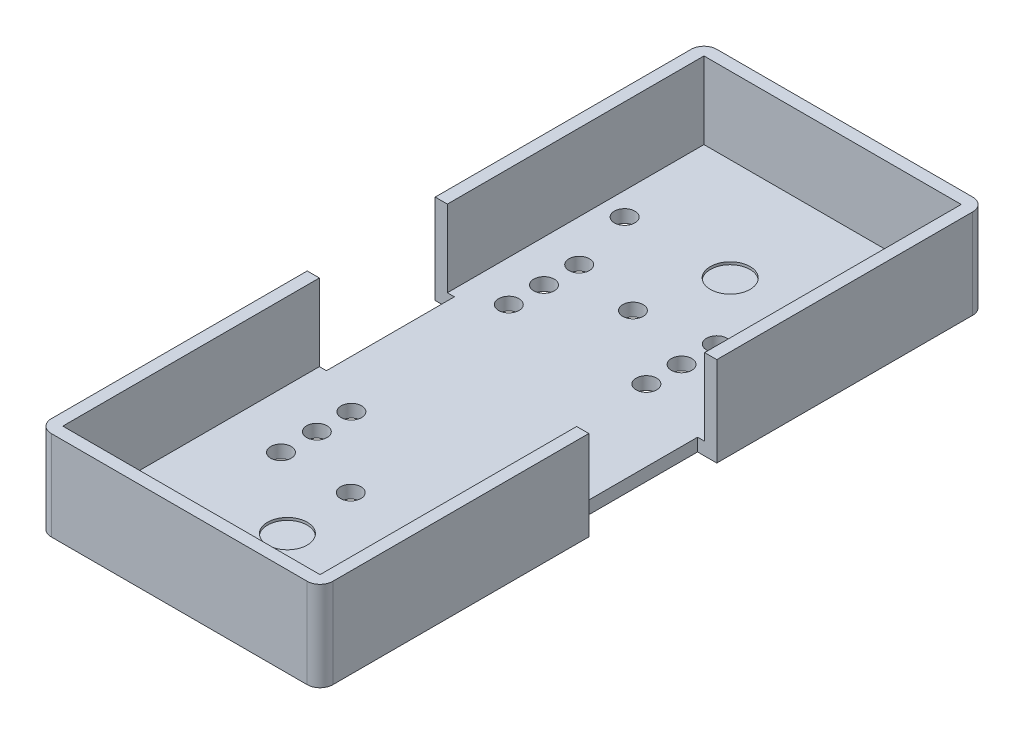
from build123d import *

# Parameters (mm, degrees)
SKETCH1_W               = 22
SKETCH1_H               = 52
BOSS_EXTRUDE1_DEPTH     = 7
SKETCH2_W               = 20.1
SKETCH2_H               = 50.1
CUT_EXTRUDE1_DEPTH      = 6
FILLET1_R               = 1
SKETCH4_W               = 1.5
SKETCH4_H               = 10
CUT_EXTRUDE3_DEPTH      = 8
SKETCH5_R               = 1.55
CUT_EXTRUDE4_DEPTH      = 0.2
SKETCH6_R               = 1.55
CUT_EXTRUDE5_DEPTH      = 0.2
SKETCH7_R               = 0.8
CUT_EXTRUDE6_DEPTH      = 7
CUT_EXTRUDE6_DEPTH_BACK = 2
CUT_EXTRUDE7_REACH      = 3
SKETCH8_R               = 0.8
CUT_EXTRUDE9_REACH      = 3
SKETCH9_R               = 0.8
CUT_EXTRUDE10_REACH     = 3
SKETCH10_R              = 0.8
CUT_EXTRUDE11_REACH     = 3
SKETCH11_R              = 0.8
CUT_EXTRUDE12_REACH     = 3
SKETCH12_R              = 0.8
CUT_EXTRUDE13_REACH     = 3
SKETCH13_R              = 0.8
CUT_EXTRUDE14_REACH     = 3
SKETCH14_R              = 0.8
CUT_EXTRUDE15_REACH     = 3
SKETCH15_R              = 0.8
CUT_EXTRUDE16_REACH     = 3
SKETCH16_R              = 0.8


with BuildPart() as part:
    # Sketch1 → Boss-Extrude1 (new body)
    with BuildSketch(Plane(origin=(0, 0, 0), x_dir=(1, 0, 0), z_dir=(0, 1, 0))):
        Rectangle(SKETCH1_W, SKETCH1_H)
    extrude(amount=BOSS_EXTRUDE1_DEPTH)

    # Sketch2 → Cut-Extrude1 (cut)
    with BuildSketch(Plane(origin=(0, 7, 0), x_dir=(1, 0, 0), z_dir=(0, 1, 0))):
        Rectangle(SKETCH2_W, SKETCH2_H)
    extrude(amount=-CUT_EXTRUDE1_DEPTH, mode=Mode.SUBTRACT)

    # Fillet1
    fillet1_edges = [part.edges().sort_by_distance(p)[0] for p in [
        (11, 3.5, 26),
        (-11, 3.5, 26),
        (-11, 3.5, -26),
        (11, 3.5, -26),
    ]]
    fillet(fillet1_edges, radius=FILLET1_R)

    # Sketch4 → Cut-Extrude3 (cut, through all)
    with BuildSketch(Plane.XZ):
        with Locations((-10.25, 0)):
            Rectangle(SKETCH4_W, SKETCH4_H)
        with Locations((10.25, 0)):
            Rectangle(SKETCH4_W, SKETCH4_H)
    extrude(amount=-CUT_EXTRUDE3_DEPTH, mode=Mode.SUBTRACT)

    # Sketch5 → Cut-Extrude4 (cut)
    with BuildSketch(Plane(origin=(0, 1, 0), x_dir=(1, 0, 0), z_dir=(0, 1, 0))):
        with Locations((0, -17.55)):
            Circle(SKETCH5_R)
    extrude(amount=-CUT_EXTRUDE4_DEPTH, mode=Mode.SUBTRACT)

    # Sketch6 → Cut-Extrude5 (cut)
    with BuildSketch(Plane(origin=(0, 1, 0), x_dir=(1, 0, 0), z_dir=(0, 1, 0))):
        with Locations((0, 17.05)):
            Circle(SKETCH6_R)
    extrude(amount=-CUT_EXTRUDE5_DEPTH, mode=Mode.SUBTRACT)

    # Sketch7 → Cut-Extrude6 (cut, two sides)
    with BuildSketch(Plane(origin=(0, 1, 0), x_dir=(1, 0, 0), z_dir=(0, 1, 0))) as cut_extrude6_sk:
        with Locations((-8.15, -23)):
            Circle(SKETCH7_R)
    extrude(amount=CUT_EXTRUDE6_DEPTH, mode=Mode.SUBTRACT)
    extrude(cut_extrude6_sk.sketch, amount=-CUT_EXTRUDE6_DEPTH_BACK, mode=Mode.SUBTRACT)

    # Sketch8 → Cut-Extrude7 (cut, up to next)
    with BuildSketch(Plane(origin=(0, 1, 0), x_dir=(1, 0, 0), z_dir=(0, 1, 0)), mode=Mode.PRIVATE) as cut_extrude7_sk1:
        with Locations((-5.75, -12.3)):
            Circle(SKETCH8_R)
    cut_extrude7_tool1 = extrude(cut_extrude7_sk1.sketch, amount=-CUT_EXTRUDE7_REACH, mode=Mode.PRIVATE) & part.part
    add(cut_extrude7_tool1.solids().sort_by_distance((-5.75, 1, 12.3))[0], mode=Mode.SUBTRACT)
    # Sketch8 → Cut-Extrude7 (cut, up to next)
    with BuildSketch(Plane(origin=(0, 1, 0), x_dir=(1, 0, 0), z_dir=(0, 1, 0)), mode=Mode.PRIVATE) as cut_extrude7_sk2:
        with Locations((5, -12.3)):
            Circle(SKETCH8_R)
    cut_extrude7_tool2 = extrude(cut_extrude7_sk2.sketch, amount=-CUT_EXTRUDE7_REACH, mode=Mode.PRIVATE) & part.part
    add(cut_extrude7_tool2.solids().sort_by_distance((5, 1, 12.3))[0], mode=Mode.SUBTRACT)

    # Sketch9 → Cut-Extrude9 (cut, up to next)
    with BuildSketch(Plane(origin=(0, 1, 0), x_dir=(1, 0, 0), z_dir=(0, 1, 0)), mode=Mode.PRIVATE) as cut_extrude9_sk1:
        with Locations((-5.75, -9.5)):
            Circle(SKETCH9_R)
    cut_extrude9_tool1 = extrude(cut_extrude9_sk1.sketch, amount=-CUT_EXTRUDE9_REACH, mode=Mode.PRIVATE) & part.part
    add(cut_extrude9_tool1.solids().sort_by_distance((-5.75, 1, 9.5))[0], mode=Mode.SUBTRACT)
    # Sketch9 → Cut-Extrude9 (cut, up to next)
    with BuildSketch(Plane(origin=(0, 1, 0), x_dir=(1, 0, 0), z_dir=(0, 1, 0)), mode=Mode.PRIVATE) as cut_extrude9_sk2:
        with Locations((5, -9.5)):
            Circle(SKETCH9_R)
    cut_extrude9_tool2 = extrude(cut_extrude9_sk2.sketch, amount=-CUT_EXTRUDE9_REACH, mode=Mode.PRIVATE) & part.part
    add(cut_extrude9_tool2.solids().sort_by_distance((5, 1, 9.5))[0], mode=Mode.SUBTRACT)

    # Sketch10 → Cut-Extrude10 (cut, up to next)
    with BuildSketch(Plane(origin=(0, 1, 0), x_dir=(1, 0, 0), z_dir=(0, 1, 0)), mode=Mode.PRIVATE) as cut_extrude10_sk1:
        with Locations((-5.75, -6.8)):
            Circle(SKETCH10_R)
    cut_extrude10_tool1 = extrude(cut_extrude10_sk1.sketch, amount=-CUT_EXTRUDE10_REACH, mode=Mode.PRIVATE) & part.part
    add(cut_extrude10_tool1.solids().sort_by_distance((-5.75, 1, 6.8))[0], mode=Mode.SUBTRACT)
    # Sketch10 → Cut-Extrude10 (cut, up to next)
    with BuildSketch(Plane(origin=(0, 1, 0), x_dir=(1, 0, 0), z_dir=(0, 1, 0)), mode=Mode.PRIVATE) as cut_extrude10_sk2:
        with Locations((5, -6.837159935)):
            Circle(SKETCH10_R)
    cut_extrude10_tool2 = extrude(cut_extrude10_sk2.sketch, amount=-CUT_EXTRUDE10_REACH, mode=Mode.PRIVATE) & part.part
    add(cut_extrude10_tool2.solids().sort_by_distance((5, 1, 6.83716))[0], mode=Mode.SUBTRACT)

    # Sketch11 → Cut-Extrude11 (cut, up to next)
    with BuildSketch(Plane(origin=(0, 1, 0), x_dir=(1, 0, 0), z_dir=(0, 1, 0)), mode=Mode.PRIVATE) as cut_extrude11_sk1:
        with Locations((-0.3, -12.3)):
            Circle(SKETCH11_R)
    cut_extrude11_tool1 = extrude(cut_extrude11_sk1.sketch, amount=-CUT_EXTRUDE11_REACH, mode=Mode.PRIVATE) & part.part
    add(cut_extrude11_tool1.solids().sort_by_distance((-0.3, 1, 12.3))[0], mode=Mode.SUBTRACT)

    # Sketch12 → Cut-Extrude12 (cut, up to next)
    with BuildSketch(Plane(origin=(0, 1, 0), x_dir=(1, 0, 0), z_dir=(0, 1, 0)), mode=Mode.PRIVATE) as cut_extrude12_sk1:
        with Locations((3.95, 12.05)):
            Circle(SKETCH12_R)
    cut_extrude12_tool1 = extrude(cut_extrude12_sk1.sketch, amount=-CUT_EXTRUDE12_REACH, mode=Mode.PRIVATE) & part.part
    add(cut_extrude12_tool1.solids().sort_by_distance((3.95, 1, -12.05))[0], mode=Mode.SUBTRACT)
    # Sketch12 → Cut-Extrude12 (cut, up to next)
    with BuildSketch(Plane(origin=(0, 1, 0), x_dir=(1, 0, 0), z_dir=(0, 1, 0)), mode=Mode.PRIVATE) as cut_extrude12_sk2:
        with Locations((-6.8, 12.05)):
            Circle(SKETCH12_R)
    cut_extrude12_tool2 = extrude(cut_extrude12_sk2.sketch, amount=-CUT_EXTRUDE12_REACH, mode=Mode.PRIVATE) & part.part
    add(cut_extrude12_tool2.solids().sort_by_distance((-6.8, 1, -12.05))[0], mode=Mode.SUBTRACT)

    # Sketch13 → Cut-Extrude13 (cut, up to next)
    with BuildSketch(Plane(origin=(0, 1, 0), x_dir=(1, 0, 0), z_dir=(0, 1, 0)), mode=Mode.PRIVATE) as cut_extrude13_sk1:
        with Locations((3.95, 9.3)):
            Circle(SKETCH13_R)
    cut_extrude13_tool1 = extrude(cut_extrude13_sk1.sketch, amount=-CUT_EXTRUDE13_REACH, mode=Mode.PRIVATE) & part.part
    add(cut_extrude13_tool1.solids().sort_by_distance((3.95, 1, -9.3))[0], mode=Mode.SUBTRACT)
    # Sketch13 → Cut-Extrude13 (cut, up to next)
    with BuildSketch(Plane(origin=(0, 1, 0), x_dir=(1, 0, 0), z_dir=(0, 1, 0)), mode=Mode.PRIVATE) as cut_extrude13_sk2:
        with Locations((-6.8, 9.3)):
            Circle(SKETCH13_R)
    cut_extrude13_tool2 = extrude(cut_extrude13_sk2.sketch, amount=-CUT_EXTRUDE13_REACH, mode=Mode.PRIVATE) & part.part
    add(cut_extrude13_tool2.solids().sort_by_distance((-6.8, 1, -9.3))[0], mode=Mode.SUBTRACT)

    # Sketch14 → Cut-Extrude14 (cut, up to next)
    with BuildSketch(Plane(origin=(0, 1, 0), x_dir=(1, 0, 0), z_dir=(0, 1, 0)), mode=Mode.PRIVATE) as cut_extrude14_sk1:
        with Locations((3.9, 6.6)):
            Circle(SKETCH14_R)
    cut_extrude14_tool1 = extrude(cut_extrude14_sk1.sketch, amount=-CUT_EXTRUDE14_REACH, mode=Mode.PRIVATE) & part.part
    add(cut_extrude14_tool1.solids().sort_by_distance((3.9, 1, -6.6))[0], mode=Mode.SUBTRACT)
    # Sketch14 → Cut-Extrude14 (cut, up to next)
    with BuildSketch(Plane(origin=(0, 1, 0), x_dir=(1, 0, 0), z_dir=(0, 1, 0)), mode=Mode.PRIVATE) as cut_extrude14_sk2:
        with Locations((-6.85, 6.6)):
            Circle(SKETCH14_R)
    cut_extrude14_tool2 = extrude(cut_extrude14_sk2.sketch, amount=-CUT_EXTRUDE14_REACH, mode=Mode.PRIVATE) & part.part
    add(cut_extrude14_tool2.solids().sort_by_distance((-6.85, 1, -6.6))[0], mode=Mode.SUBTRACT)

    # Sketch15 → Cut-Extrude15 (cut, up to next)
    with BuildSketch(Plane(origin=(0, 1, 0), x_dir=(1, 0, 0), z_dir=(0, 1, 0)), mode=Mode.PRIVATE) as cut_extrude15_sk1:
        with Locations((-1.6, 11.05)):
            Circle(SKETCH15_R)
    cut_extrude15_tool1 = extrude(cut_extrude15_sk1.sketch, amount=-CUT_EXTRUDE15_REACH, mode=Mode.PRIVATE) & part.part
    add(cut_extrude15_tool1.solids().sort_by_distance((-1.6, 1, -11.05))[0], mode=Mode.SUBTRACT)

    # Sketch16 → Cut-Extrude16 (cut, up to next)
    with BuildSketch(Plane(origin=(0, 1, 0), x_dir=(1, 0, 0), z_dir=(0, 1, 0)), mode=Mode.PRIVATE) as cut_extrude16_sk1:
        with Locations((-8.25, 17.05)):
            Circle(SKETCH16_R)
    cut_extrude16_tool1 = extrude(cut_extrude16_sk1.sketch, amount=-CUT_EXTRUDE16_REACH, mode=Mode.PRIVATE) & part.part
    add(cut_extrude16_tool1.solids().sort_by_distance((-8.25, 1, -17.05))[0], mode=Mode.SUBTRACT)


solid = part.part
